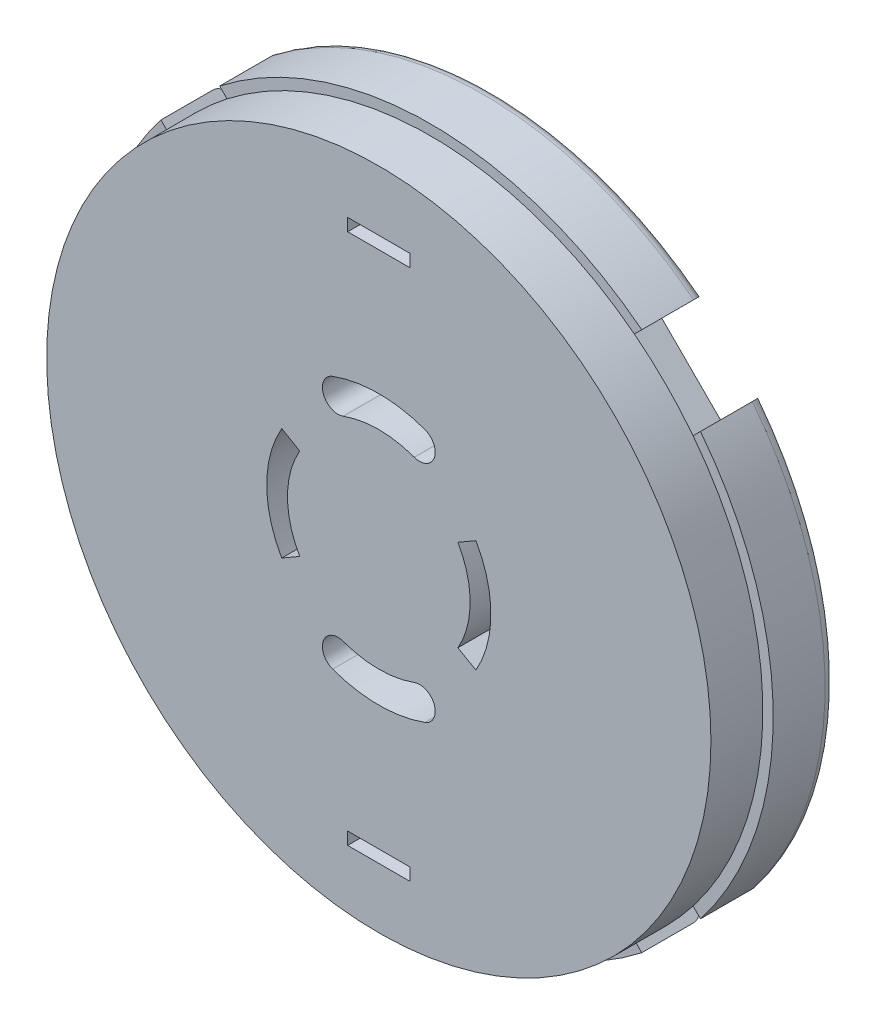
from build123d import *

# Parameters (mm, degrees)
SKETCH1_R           = 16.5
BOSS_EXTRUDE1_DEPTH = 3
SKETCH2_R           = 3.75
BOSS_EXTRUDE2_DEPTH = 3
CUT_EXTRUDE1_DEPTH  = 4
CIRPATTERN1_COUNT   = 4
SKETCH4_R           = 16
BOSS_EXTRUDE3_DEPTH = 2.5
CUT_EXTRUDE2_DEPTH  = 6.5
CIRPATTERN2_COUNT   = 2
CUT_EXTRUDE3_DEPTH  = 6.5
CIRPATTERN3_COUNT   = 2
SKETCH8_R           = 1.45
CUT_EXTRUDE4_DEPTH  = 0.5
SKETCH9_W           = 0.5
SKETCH9_H           = 2.9
EXTRUDE_THIN1_DEPTH = 0.5
SKETCH10_W          = 2.9
SKETCH10_H          = 0.5
EXTRUDE_THIN2_DEPTH = 0.5
SKETCH11_W          = 3
SKETCH11_H          = 0.6
CUT_EXTRUDE5_DEPTH  = 6.5
CIRPATTERN4_COUNT   = 2
FILLET1_R           = 0.1
FILLET2_R           = 0.5


with BuildPart() as part:
    # Sketch1 → Boss-Extrude1 (new body)
    with BuildSketch(Plane.XY):
        Circle(SKETCH1_R)
    extrude(amount=-BOSS_EXTRUDE1_DEPTH)

    # Sketch2 → Boss-Extrude2 (add)
    with BuildSketch(Plane(origin=(0, 0, -3), x_dir=(-1, 0, 0), z_dir=(0, 0, -1))):
        Circle(SKETCH2_R)
    extrude(amount=BOSS_EXTRUDE2_DEPTH)

    # Sketch3 → Cut-Extrude1 (cut, through all)
    with BuildSketch(Plane(origin=(0, 0, -3), x_dir=(-1, 0, 0), z_dir=(0, 0, -1))):
        Polygon((10.253048327, 13.081475452), (8.131727984, 10.960155108), (10.960155108, 8.131727984), (13.081475452, 10.253048327), align=None)
    cut_extrude1 = extrude(amount=-CUT_EXTRUDE1_DEPTH, mode=Mode.SUBTRACT)

    # CirPattern1: Cut-Extrude1 ×4 about axis
    cirpattern1_axis = Axis((0, 0, 0), (0, 0, 1))
    for i in range(1, CIRPATTERN1_COUNT):
        add(cut_extrude1.rotate(cirpattern1_axis, i * 360 / CIRPATTERN1_COUNT), mode=Mode.SUBTRACT)

    # Sketch4 → Boss-Extrude3 (add)
    with BuildSketch(Plane.XY):
        Circle(SKETCH4_R)
    extrude(amount=BOSS_EXTRUDE3_DEPTH)

    # Sketch6 → Cut-Extrude2 (cut, through all)
    with BuildSketch(Plane(origin=(0, 0, -3), x_dir=(-1, 0, 0), z_dir=(0, 0, -1))):
        with BuildLine():
            Line((-4.67653718, 2.7), (-3.810511777, 2.2))
            ThreePointArc((-3.810511777, 2.2), (-4.4, 0), (-3.810511777, -2.2))
            Line((-3.810511777, -2.2), (-4.67653718, -2.7))
            ThreePointArc((-4.67653718, -2.7), (-5.4, 0), (-4.67653718, 2.7))
        make_face()
    cut_extrude2 = extrude(amount=-CUT_EXTRUDE2_DEPTH, mode=Mode.SUBTRACT)

    # CirPattern2: Cut-Extrude2 ×2 about axis
    cirpattern2_axis = Axis((0, 0, 0), (0, 0, 1))
    for i in range(1, CIRPATTERN2_COUNT):
        add(cut_extrude2.rotate(cirpattern2_axis, i * 360 / CIRPATTERN2_COUNT), mode=Mode.SUBTRACT)

    # Sketch7 → Cut-Extrude3 (cut, through all)
    with BuildSketch(Plane(origin=(0, 0, -3), x_dir=(-1, 0, 0), z_dir=(0, 0, -1))):
        with BuildLine():
            ThreePointArc((2.223130932, 6.108002035), (0, 6.5), (-2.223130932, 6.108002035))
            ThreePointArc((-2.223130932, 6.108002035), (-2.67138529, 5.146717462), (-1.710100717, 4.698463104))
            ThreePointArc((-1.710100717, 4.698463104), (0, 5), (1.710100717, 4.698463104))
            ThreePointArc((1.710100717, 4.698463104), (2.67138529, 5.146717462), (2.223130932, 6.108002035))
        make_face()
    cut_extrude3 = extrude(amount=-CUT_EXTRUDE3_DEPTH, mode=Mode.SUBTRACT)

    # CirPattern3: Cut-Extrude3 ×2 about axis
    cirpattern3_axis = Axis((0, 0, 0), (0, 0, 1))
    for i in range(1, CIRPATTERN3_COUNT):
        add(cut_extrude3.rotate(cirpattern3_axis, i * 360 / CIRPATTERN3_COUNT), mode=Mode.SUBTRACT)

    # Sketch8 → Cut-Extrude4 (cut)
    with BuildSketch(Plane(origin=(0, 0, -3), x_dir=(-1, 0, 0), z_dir=(0, 0, -1))):
        with Locations((-7.071067812, 7.071067812)):
            Circle(SKETCH8_R)
        Polygon((8.485281374, -3.535533906), (3.535533906, -8.485281374), (5.656854249, -10.606601718), (10.606601718, -5.656854249), align=None)
    extrude(amount=-CUT_EXTRUDE4_DEPTH, mode=Mode.SUBTRACT)

    # Sketch9 → Extrude-Thin1 (add)
    with BuildSketch(Plane(origin=(0, 0, -2.5), x_dir=(-1, 0, 0), z_dir=(0, 0, -1))):
        with Locations((-7.071067812, 7.071067812)):
            Rectangle(SKETCH9_W, SKETCH9_H)
    extrude(amount=EXTRUDE_THIN1_DEPTH)

    # Sketch10 → Extrude-Thin2 (add)
    with BuildSketch(Plane(origin=(0, 0, -2.5), x_dir=(-1, 0, 0), z_dir=(0, 0, -1))):
        with Locations((-7.071067812, 7.071067812)):
            Rectangle(SKETCH10_W, SKETCH10_H)
    extrude(amount=EXTRUDE_THIN2_DEPTH)

    # Sketch11 → Cut-Extrude5 (cut, through all)
    with BuildSketch(Plane(origin=(0, 0, -3), x_dir=(-1, 0, 0), z_dir=(0, 0, -1))):
        with Locations((0, 12.8)):
            Rectangle(SKETCH11_W, SKETCH11_H)
    cut_extrude5 = extrude(amount=-CUT_EXTRUDE5_DEPTH, mode=Mode.SUBTRACT)

    # CirPattern4: Cut-Extrude5 ×2 about axis
    cirpattern4_axis = Axis((0, 0, 0), (0, 0, 1))
    for i in range(1, CIRPATTERN4_COUNT):
        add(cut_extrude5.rotate(cirpattern4_axis, i * 360 / CIRPATTERN4_COUNT), mode=Mode.SUBTRACT)

    # Fillet1
    fillet1_edges = [part.edges().sort_by_distance(p)[0] for p in [
        (3.75, 0, -3),
        (3.75, 0, -6),
    ]]
    fillet(fillet1_edges, radius=FILLET1_R)

    # Fillet2
    fillet2_edges = [part.edges().sort_by_distance(p)[0] for p in [
        (-16.5, 0, -3),
        (0, -16.5, -3),
        (16.5, 0, -3),
        (0, 16.5, -3),
    ]]
    fillet(fillet2_edges, radius=FILLET2_R)


solid = part.part
